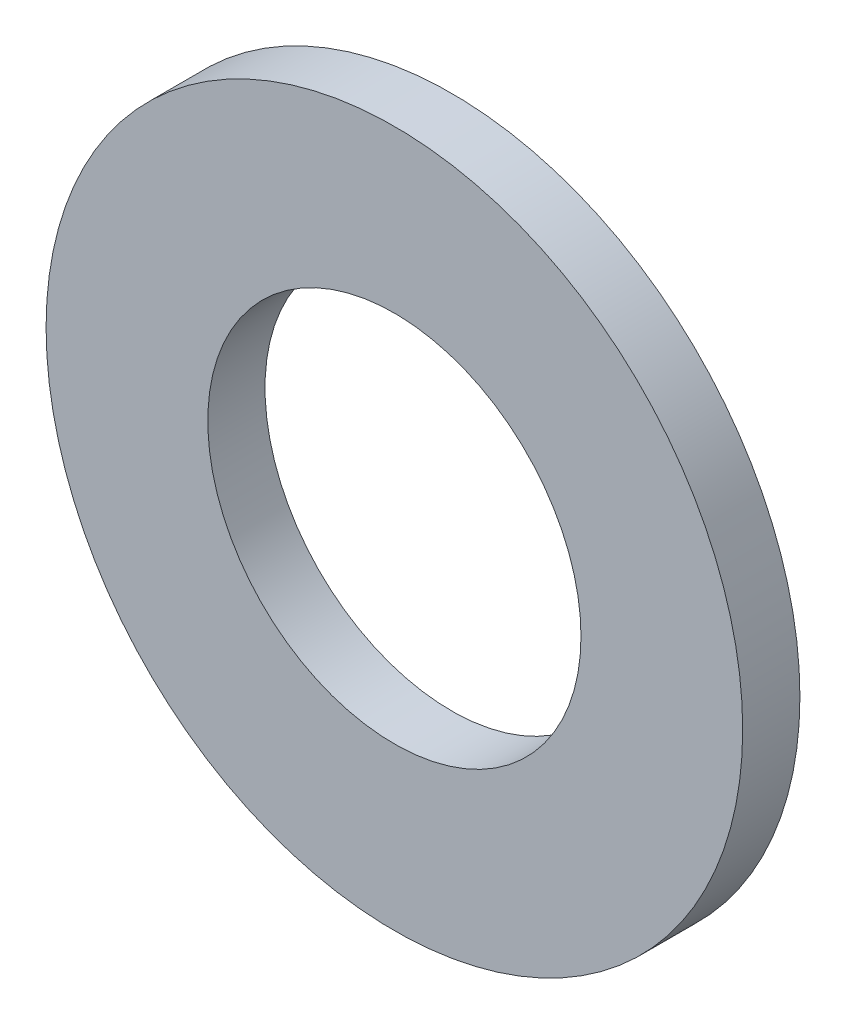
from build123d import *

# Parameters (mm, degrees)
SKETCH1_R      = 14
SKETCH1_R_2    = 7.5
EXTRUDE1_DEPTH = 2.3


with BuildPart() as part:
    # Sketch1 → Extrude1 (new body)
    with BuildSketch(Plane.XY):
        Circle(SKETCH1_R)
        Circle(SKETCH1_R_2, mode=Mode.SUBTRACT)
    extrude(amount=-EXTRUDE1_DEPTH)


solid = part.part
